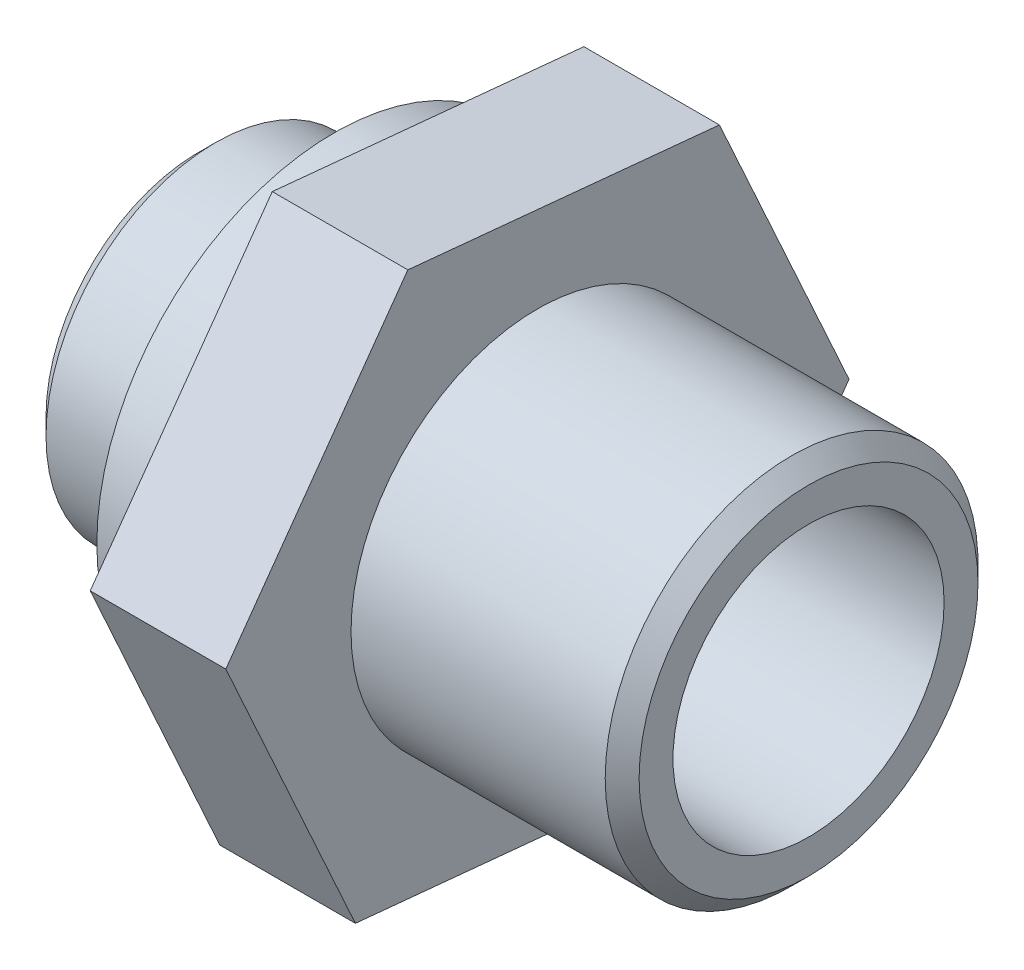
from build123d import *

# Parameters (mm, degrees)
BOSS_EXTRUDE2_DEPTH = 2
SKETCH9_R           = 2
CUT_EXTRUDE1_DEPTH  = 10


with BuildPart() as part:
    # Sketch1 → Revolve1 (revolve)
    with BuildSketch(Plane.XY):
        Polygon((-4.5, 0), (-1.5, 0), (-1.5, -3.5), (-2.5, -3.5), (-2.5, -2.5), (-4.25, -2.5), (-4.5, -2.25), align=None)
        Polygon((0.5, -2.75), (4.25, -2.75), (4.5, -2.5), (4.5, 0), (0.5, 0), align=None)
    revolve(axis=Axis((-4.5, 0, 0), (1, 0, 0)))

    # Sketch5 → Boss-Extrude2 (add)
    with BuildSketch(Plane(origin=(-1.5, 0, 0), x_dir=(0, 0, -1), z_dir=(1, 0, 0))):
        Polygon((1.911716384, -4.204601503), (4.597149907, -0.446705798), (2.685433523, 3.757895705), (-1.911716384, 4.204601503), (-4.597149907, 0.446705798), (-2.685433523, -3.757895705), align=None)
    extrude(amount=BOSS_EXTRUDE2_DEPTH)

    # Sketch9 → Cut-Extrude1 (cut)
    with BuildSketch(Plane(origin=(4.5, 0, 0), x_dir=(0, 0, -1), z_dir=(1, 0, 0))):
        Circle(SKETCH9_R)
    extrude(amount=-CUT_EXTRUDE1_DEPTH, mode=Mode.SUBTRACT)


solid = part.part
